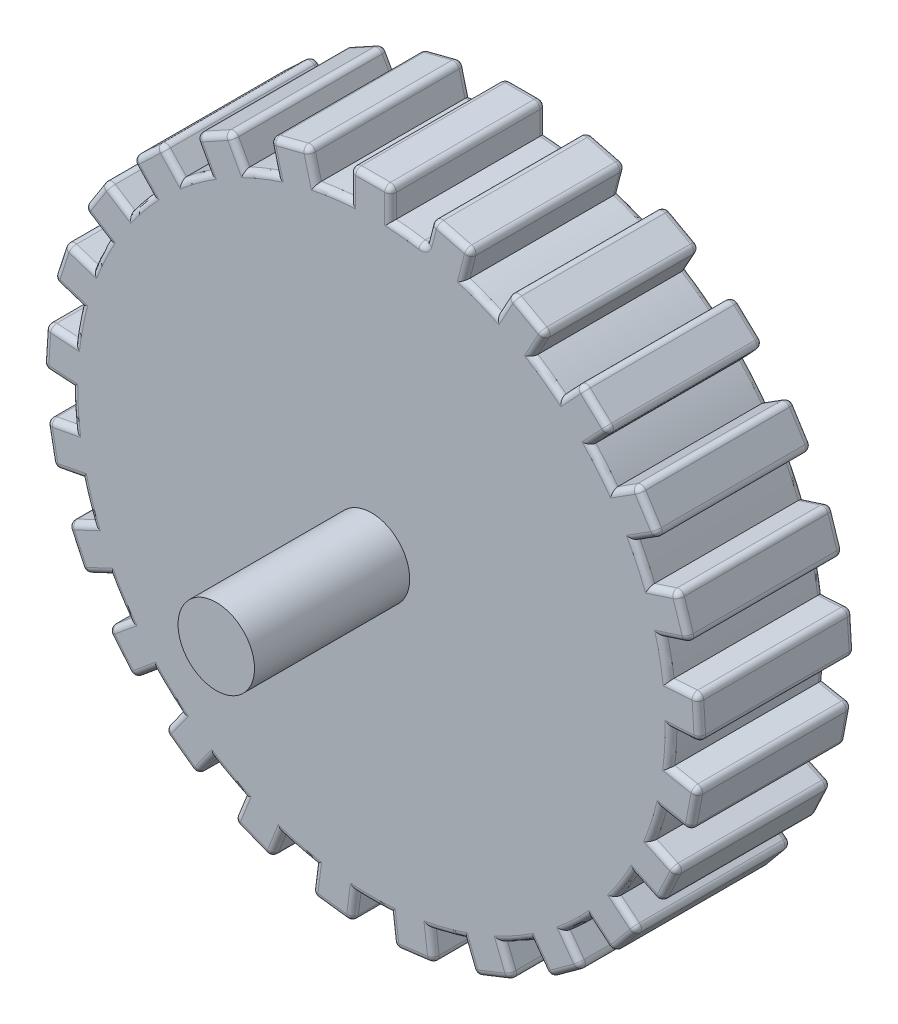
from build123d import *

# Parameters (mm, degrees)
BOSS_EXTRUDE4_DEPTH = 4.064
CIRPATTERN4_COUNT   = 25
FILLET5_R           = 0.1524
SKETCH5_R           = 1.000884326
BOSS_EXTRUDE5_DEPTH = 4.064
SKETCH6_R           = 0.983007086
BOSS_EXTRUDE6_DEPTH = 4.064


with BuildPart() as part:
    # Sketch1 → Boss-Extrude4 (new body)
    with BuildSketch(Plane.XY):
        with BuildLine():
            Line((0, 8.59179196), (-0.566428755, 8.59179196))
            Line((-0.566428755, 8.59179196), (-0.566428755, 7.824170896))
            ThreePointArc((-0.566428755, 7.824170896), (0.033816187, -7.844574445), (0.498952494, 7.828763514))
            Line((0.498952494, 7.828763514), (0.498952494, 8.59179196))
            Line((0.498952494, 8.59179196), (0, 8.59179196))
        make_face()
    boss_extrude4 = extrude(amount=BOSS_EXTRUDE4_DEPTH)

    # CirPattern4: Boss-Extrude4 ×25 about axis
    cirpattern4_axis = Axis((0, 0, 0), (0, 0, 1))
    for i in range(1, CIRPATTERN4_COUNT):
        add(boss_extrude4.rotate(cirpattern4_axis, i * 360 / CIRPATTERN4_COUNT))

    # Fillet5
    fillet5_edges = [part.edges().sort_by_distance(p)[0] for p in [
        (1.397158823, 7.719225283, 2.032),
        (-2.169369958, 8.313474685, 0),
        (-1.65341479, 8.445949456, 2.032),
        (-2.589875329, 7.809247495, 0),
        (-2.685325127, 8.180999914, 2.032),
        (-1.55853606, 8.076421204, 0),
        (-5.90608036, 6.240051453, 0),
        (-5.517765607, 6.604703278, 2.032),
        (-6.031658724, 5.595613791, 0),
        (-6.294395113, 5.875399628, 2.032),
        (-5.256601149, 6.326591378, 0),
        (-8.181705386, 2.622922859, 0),
        (-8.017094931, 3.129541748, 2.032),
        (-7.981290335, 1.997699993, 0),
        (-8.346315842, 2.11630397, 2.032),
        (-7.654253343, 3.01164737, 0),
        (-8.433285808, -1.643081808, 0),
        (-8.533102078, -1.119826599, 2.032),
        (-7.956457347, -2.094418095, 0),
        (-8.333469539, -2.166337017, 2.032),
        (-8.15834552, -1.048337962, 0),
        (-6.598583991, -5.502609987, 0),
        (-6.938133774, -5.092164807, 2.032),
        (-5.96330311, -5.668405127, 0),
        (-6.259034208, -5.913055167, 2.032),
        (-6.644172013, -4.848978488, 0),
        (-3.131480652, -8.000865971, 0),
        (-3.626763868, -7.804769473, 2.032),
        (-2.494907355, -7.840104461, 0),
        (-2.636197435, -8.196962469, 2.032),
        (-3.486319116, -7.450046519, 0),
        (1.110309164, -8.519814606, 0),
        (0.581818964, -8.586578444, 2.032),
        (1.590695148, -8.072266696, 0),
        (1.638799364, -8.453050767, 2.032),
        (0.534002553, -8.208072574, 0),
        (-0.566428755, 8.207981428, 4.064),
        (5.077423326, -6.931074933, 0),
        (4.646467558, -7.244182626, 2.032),
        (5.282780924, -6.307457997, 0),
        (5.508379094, -6.61796724, 2.032),
        (4.422219124, -6.935531135, 0),
        (7.788450792, -3.627679921, 0),
        (7.561642156, -4.109672808, 2.032),
        (7.667977277, -2.982268457, 0),
        (8.015259429, -3.145687033, 2.032),
        (7.216437766, -3.947231953, 0),
        (8.572719587, 0.573154637, 0),
        (8.606167508, 0.041515156, 2.032),
        (8.156218496, 1.080694455, 0),
        (8.539271666, 1.104794118, 2.032),
        (8.225406116, 0.01755968, 0),
        (7.236212088, 4.632198395, 0),
        (7.521641998, 4.182432825, 2.032),
        (6.626720228, 4.876307998, 0),
        (6.950782178, 5.081963965, 2.032),
        (7.199518885, 3.978007282, 0),
        (4.109562395, 7.545298157, 0),
        (4.576362747, 7.288672491, 2.032),
        (3.457859908, 7.465588089, 0),
        (3.642762042, 7.801923822, 2.032),
        (4.392566869, 6.954349029, 0),
        (2.104013588, 8.330255349, 0),
        (2.619968757, 8.197780577, 2.032),
        (1.492608621, 8.090977702, 0),
        (1.588058419, 8.46273012, 2.032),
        (2.525090028, 7.828252325, 0),
        (5.856892283, 6.286242132, 0),
        (6.245207036, 5.921590307, 2.032),
        (5.20584114, 6.371108121, 0),
        (5.468577529, 6.650893957, 2.032),
        (5.984042578, 5.643478407, 0),
        (8.160854075, 2.687096597, 0),
        (8.325464531, 2.180477707, 2.032),
        (7.631218112, 3.075111509, 0),
        (7.996243619, 3.193715486, 2.032),
        (7.962622943, 2.062583329, 0),
        (8.445929599, -1.576800737, 0),
        (8.346113329, -2.100055946, 2.032),
        (8.168733676, -0.981626606, 0),
        (8.545745868, -1.053545528, 2.032),
        (7.971356772, -2.028567309, 0),
        (6.641594979, -5.450618634, 0),
        (6.302045195, -5.861063814, 2.032),
        (6.685413664, -4.795523413, 0),
        (6.981144762, -5.040173454, 2.032),
        (6.008083434, -5.617877496, 0),
        (3.194218493, -7.976026302, 0),
        (2.698935276, -8.1721228, 2.032),
        (3.548211629, -7.423071797, 0),
        (3.689501709, -7.779929804, 2.032),
        (2.558490523, -7.817399846, 0),
        (-1.043364973, -8.528271624, 0),
        (-1.571855173, -8.461507785, 2.032),
        (-0.466770558, -8.214251391, 0),
        (-0.514874773, -8.595035462, 2.032),
        (-1.524038762, -8.083001916, 0),
        (-5.022833884, -6.970736484, 0),
        (-5.453789652, -6.657628791, 2.032),
        (-4.366279946, -6.973334934, 0),
        (-4.591878116, -7.283844177, 2.032),
        (-5.229541218, -6.348977301, 0),
        (-7.759720798, -3.688734267, 0),
        (-7.986529434, -3.20674138, 2.032),
        (-7.185630009, -4.007308579, 0),
        (-7.532912161, -4.170727155, 2.032),
        (-7.641325044, -3.044300524, 0),
        (-8.576956456, 0.505811525, 0),
        (-8.543508535, 1.037451006, 2.032),
        (-8.227351208, -0.049927619, 0),
        (-8.610404377, -0.025827956, 2.032),
        (-8.162747143, 1.01349553, 0),
        (-7.272367677, 4.575226303, 0),
        (-6.986937767, 5.024991873, 2.032),
        (-7.233735636, 3.919804766, 0),
        (-7.557797587, 4.125460734, 2.032),
        (-6.664814654, 4.82056633, 0),
        (-4.168692293, 7.51279122, 0),
        (-3.701891941, 7.769416886, 2.032),
        (-4.450590512, 6.919829822, 0),
        (-4.635492646, 7.256165555, 2.032),
        (-3.518096062, 7.435093423, 0),
        (-1.016735417, 7.77847934, 4.064),
        (-2.919221954, 7.281252292, 0),
        (-4.638283039, 6.326517383, 0),
        (-6.065903742, 4.974264121, 0),
        (-7.112381405, 3.309459549, 0),
        (-7.711961986, 1.436709463, 0),
        (-7.826971633, -0.526314363, 0),
        (0.498952494, 8.210277737, 4.064),
        (-7.450183867, -2.456267922, 0),
        (-6.605273648, -4.231885133, 0),
        (-5.345329794, -5.741597438, 0),
        (-3.74951921, -6.89054406, 0),
        (-1.918112544, -7.606532457, 0),
        (0.033816187, -7.844574445, 0),
        (1.983620123, -7.58971297, 0),
        (3.808785911, -6.857961916, 0),
        (5.394631673, -5.695299893, 0),
        (6.641512886, -4.174781232, 0),
        (7.47108342, -2.391945712, 0),
        (7.831218305, -0.458815447, 0),
        (7.699288943, 1.503143881, 0),
        (7.08358494, 3.37065515, 0),
        (6.022793245, 5.02637576, 0),
        (4.583567299, 6.366270695, 0),
        (2.856338963, 7.306149429, 0),
        (0.949636345, 7.786955924, 0),
        (-2.919221954, 7.281252292, 4.064),
        (-4.638283039, 6.326517383, 4.064),
        (-6.065903742, 4.974264121, 4.064),
        (-7.112381405, 3.309459549, 4.064),
        (-7.711961986, 1.436709463, 4.064),
        (-7.826971633, -0.526314363, 4.064),
        (-7.450183867, -2.456267922, 4.064),
        (-6.605273648, -4.231885133, 4.064),
        (-5.345329794, -5.741597438, 4.064),
        (-3.74951921, -6.89054406, 4.064),
        (-1.918112544, -7.606532457, 4.064),
        (0.033816187, -7.844574445, 4.064),
        (1.983620123, -7.58971297, 4.064),
        (3.808785911, -6.857961916, 4.064),
        (5.394631673, -5.695299893, 4.064),
        (6.641512886, -4.174781232, 4.064),
        (7.47108342, -2.391945712, 4.064),
        (7.831218305, -0.458815447, 4.064),
        (7.699288943, 1.503143881, 4.064),
        (7.08358494, 3.37065515, 4.064),
        (6.022793245, 5.02637576, 4.064),
        (4.583567299, 6.366270695, 4.064),
        (2.856338963, 7.306149429, 4.064),
        (0.949636345, 7.786955924, 4.064),
        (-0.033738131, 8.59179196, 4.064),
        (0.498952494, 8.210277737, 0),
        (-1.016735417, 7.77847934, 0),
        (-0.566428755, 8.207981428, 0),
        (-0.033738131, 8.59179196, 0),
        (7.962622943, 2.062583329, 4.064),
        (8.160854075, 2.687096597, 4.064),
        (7.631218112, 3.075111509, 4.064),
        (7.199518885, 3.978007282, 4.064),
        (7.236212088, 4.632198395, 4.064),
        (6.626720228, 4.876307998, 4.064),
        (5.984042578, 5.643478407, 4.064),
        (5.856892283, 6.286242132, 4.064),
        (5.20584114, 6.371108121, 4.064),
        (4.392566869, 6.954349029, 4.064),
        (4.109562395, 7.545298157, 4.064),
        (3.457859908, 7.465588089, 4.064),
        (2.525090028, 7.828252325, 4.064),
        (2.104013588, 8.330255349, 4.064),
        (1.492608621, 8.090977702, 4.064),
        (-1.55853606, 8.076421204, 4.064),
        (-2.169369958, 8.313474685, 4.064),
        (-2.589875329, 7.809247495, 4.064),
        (-3.518096062, 7.435093423, 4.064),
        (-4.168692293, 7.51279122, 4.064),
        (-4.450590512, 6.919829822, 4.064),
        (-5.256601149, 6.326591378, 4.064),
        (-5.90608036, 6.240051453, 4.064),
        (-6.031658724, 5.595613791, 4.064),
        (-6.664814654, 4.82056633, 4.064),
        (-7.272367677, 4.575226303, 4.064),
        (-7.233735636, 3.919804766, 4.064),
        (-7.654253343, 3.01164737, 4.064),
        (-8.181705386, 2.622922859, 4.064),
        (-7.981290335, 1.997699993, 4.064),
        (-8.162747143, 1.01349553, 4.064),
        (-8.576956456, 0.505811525, 4.064),
        (-8.227351208, -0.049927619, 4.064),
        (-8.15834552, -1.048337962, 4.064),
        (-8.433285808, -1.643081808, 4.064),
        (-7.956457347, -2.094418095, 4.064),
        (-7.641325044, -3.044300524, 4.064),
        (-7.759720798, -3.688734267, 4.064),
        (-7.185630009, -4.007308579, 4.064),
        (-6.644172013, -4.848978488, 4.064),
        (-6.598583991, -5.502609987, 4.064),
        (-5.96330311, -5.668405127, 4.064),
        (-5.229541218, -6.348977301, 4.064),
        (-5.022833884, -6.970736484, 4.064),
        (-4.366279946, -6.973334934, 4.064),
        (-3.486319116, -7.450046519, 4.064),
        (-3.131480652, -8.000865971, 4.064),
        (-2.494907355, -7.840104461, 4.064),
        (-1.524038762, -8.083001916, 4.064),
        (-1.043364973, -8.528271624, 4.064),
        (-0.466770558, -8.214251391, 4.064),
        (0.534002553, -8.208072574, 4.064),
        (1.110309164, -8.519814606, 4.064),
        (1.590695148, -8.072266696, 4.064),
        (2.558490523, -7.817399846, 4.064),
        (3.194218493, -7.976026302, 4.064),
        (3.548211629, -7.423071797, 4.064),
        (4.422219124, -6.935531135, 4.064),
        (5.077423326, -6.931074933, 4.064),
        (5.282780924, -6.307457997, 4.064),
        (6.008083434, -5.617877496, 4.064),
        (6.641594979, -5.450618634, 4.064),
        (6.685413664, -4.795523413, 4.064),
        (7.216437766, -3.947231953, 4.064),
        (7.788450792, -3.627679921, 4.064),
        (0.498952494, 8.59179196, 2.032),
        (7.667977277, -2.982268457, 4.064),
        (7.971356772, -2.028567309, 4.064),
        (8.445929599, -1.576800737, 4.064),
        (8.168733676, -0.981626606, 4.064),
        (8.225406116, 0.01755968, 4.064),
        (8.572719587, 0.573154637, 4.064),
        (8.156218496, 1.080694455, 4.064),
        (-0.566428755, 8.59179196, 2.032),
    ]]
    fillet(fillet5_edges, radius=FILLET5_R)

    # Sketch5 → Boss-Extrude5 (add)
    with BuildSketch(Plane.XY.offset(4.064)):
        Circle(SKETCH5_R)
    extrude(amount=BOSS_EXTRUDE5_DEPTH)

    # Sketch6 → Boss-Extrude6 (add)
    with BuildSketch(Plane(origin=(0, 0, 0), x_dir=(-1, 0, 0), z_dir=(0, 0, -1))):
        Circle(SKETCH6_R)
    extrude(amount=BOSS_EXTRUDE6_DEPTH)


solid = part.part
